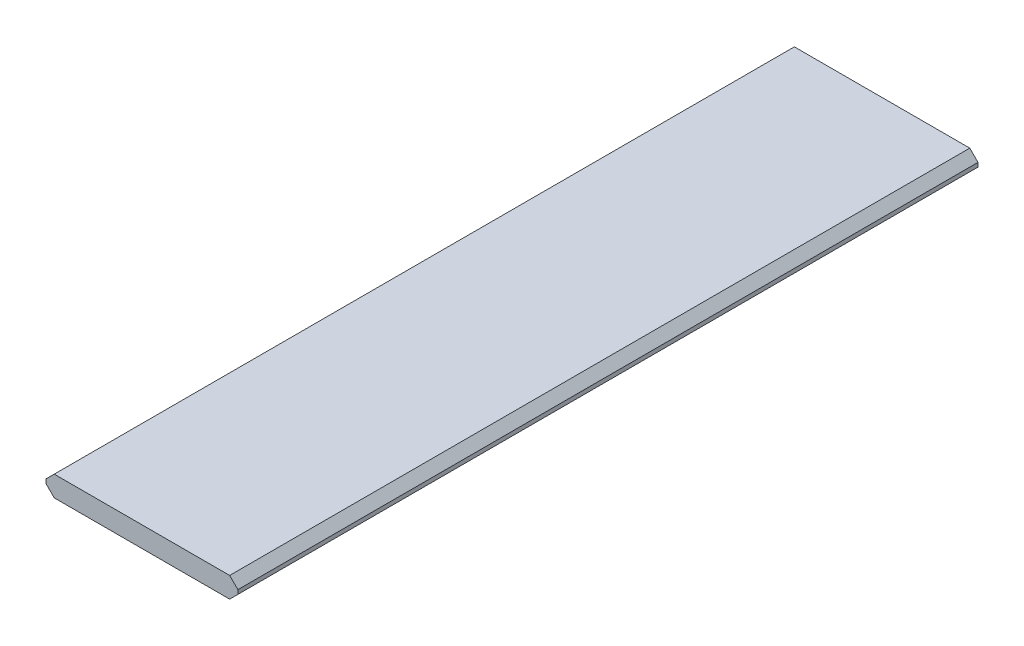
from build123d import *

# Parameters (mm, degrees)
SKETCH1_W           = 177.8
SKETCH1_H           = 685.8
BOSS_EXTRUDE1_DEPTH = 19.05
CHAMFER1_SIZE       = 7.62


with BuildPart() as part:
    # Sketch1 → Boss-Extrude1 (new body)
    with BuildSketch(Plane(origin=(0, 0, 0), x_dir=(1, 0, 0), z_dir=(0, 1, 0))):
        Rectangle(SKETCH1_W, SKETCH1_H)
    extrude(amount=BOSS_EXTRUDE1_DEPTH)

    # Chamfer1
    chamfer1_edges = [part.edges().sort_by_distance(p)[0] for p in [
        (-88.9, 19.05, 0),
        (88.9, 19.05, 0),
        (-88.9, 0, 0),
        (88.9, 0, 0),
    ]]
    chamfer(chamfer1_edges, length=CHAMFER1_SIZE)


solid = part.part
